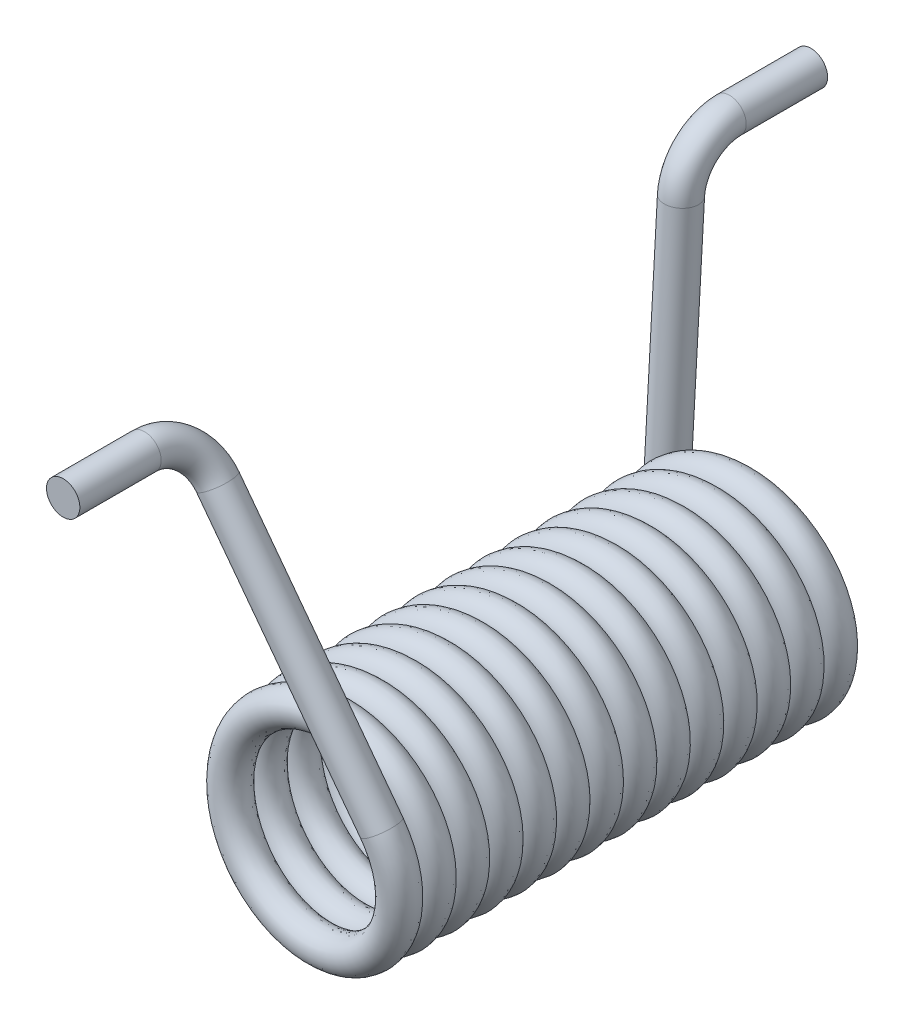
from build123d import *

# Parameters (mm, degrees)
SKIZZE2_R = 2.745


with BuildPart() as part:
    # Austragung1: sweep along a curve in space
    with BuildLine() as austragung1_path:
        Line((-15.25, 53, -10.596174722), (-15.25, 53, -23.975))
        ThreePointArc((-15.25, 45.458446529, -2.60932135), (-15.25, 50.81668171, -5.103796923), (-15.25, 53, -10.596174722))
        Line((-15.25, 0, 0), (-15.25, 45.458446529, -2.60932135))
        add(Edge.make_bspline(
            [(-15.25, 0, 0), (-15.25, -1.844708591, 0.105886538), (-14.565570074, -5.568957736, 0.319695886), (-11.620831046, -10.394587854, 0.638773055), (-7.145781306, -13.858725176, 0.958288818), (-1.729726086, -15.495884383, 1.277687059), (3.914111324, -15.092966114, 1.597116791), (9.042511718, -12.702361416, 1.916538085), (12.980132167, -8.639060495, 2.235961639), (15.208439811, -3.438098717, 2.555384588), (15.433995821, 2.215612758, 2.8748077), (13.627097435, 7.577557881, 3.194230767), (10.025689423, 11.94163803, 3.513653847), (5.104029883, 14.733161455, 3.833076923), (-0.489763308, 15.584521145, 4.1525), (-6.019061108, 14.383604236, 4.471923077), (-10.755727671, 11.288555697, 4.791346154), (-14.076006265, 6.706952741, 5.110769231), (-15.54265984, 1.24213226, 5.430192308), (-14.962549395, -4.386260713, 5.749615385), (-12.412067853, -9.437040801, 6.069038462), (-8.227080109, -13.245086649, 6.388461538), (-2.958694046, -15.308928669, 6.707884615), (2.699313135, -15.356785993, 7.027307692), (8.001856255, -13.382356441, 7.346730769), (12.250660076, -9.645646435, 7.666153846), (14.88621298, -4.638731568, 7.985576923), (15.561447288, 0.979043278, 8.305), (14.187443517, 6.467890992, 8.624423077), (10.945139905, 11.105002472, 8.943846154), (6.261505223, 14.279731083, 9.263269231), (0.753312599, 15.574006793, 9.582692308), (-4.854081393, 14.817390502, 9.902115385), (-9.822256664, 12.109518631, 10.221538462), (-13.496969829, 7.806982316, 10.540961538), (-15.394309463, 2.476369039, 10.860384615), (-15.264420872, -3.180349492, 11.179807692), (-13.124408677, -8.418257796, 11.499230769), (-9.256084358, -12.547592192, 11.818653846), (-4.168855384, -15.024573612, 12.138076923), (1.467357051, -15.523016161, 12.4575), (6.910337849, -13.977281505, 12.776923077), (11.443317976, -10.590922582, 13.096346154), (14.469363529, -5.809878355, 13.415769231), (15.589984081, -0.26374951, 13.735192308), (14.657608633, 5.31711168, 14.054615385), (11.795018777, 10.197779145, 14.374038462), (7.379179974, 13.73553313, 14.693461538), (1.991600155, 15.464497931, 15.012884615), (-3.658247228, 15.15699161, 15.332307692), (-8.826351533, 12.853508707, 15.651730769), (-12.832141348, 8.857387644, 15.971153846), (-15.148106804, 3.694865044, 16.290576923), (-15.469265691, -1.95422272, 16.61), (-13.753325603, -7.345965036, 16.929423077), (-10.226253297, -11.770340307, 17.248846154), (-5.352517839, -14.644716461, 17.568269231), (0.226073869, -15.590575937, 17.887692308), (5.77489462, -14.483361474, 18.207115385), (10.56323765, -11.468878664, 18.526538462), (13.960541118, -6.944095272, 18.845961538), (15.519424808, -1.504865802, 19.165384615), (15.034604227, 4.132534716, 19.484807692), (12.569923874, 9.225734726, 19.804230769), (8.449949757, 13.10402673, 20.123653846), (3.217228318, 15.256690644, 20.443076923), (-2.439159807, 15.400248923, 20.7625), (-7.774342643, 13.515796829, 21.081923077), (-12.085746734, 9.851491935, 21.401346154), (-14.805616826, 4.889875034, 21.720769231), (-15.575781777, -0.71567414, 22.040192308), (-14.294820986, -6.226978436, 22.359615385), (-11.131420151, -10.918271514, 22.679038462), (-6.502157587, -14.171771737, 22.998461538), (-1.016646328, -15.559035886, 23.317884615), (4.602743891, -14.897379505, 23.637307692), (9.616013234, -12.273934045, 23.956730769), (13.36298002, -8.034172791, 24.276153846), (15.350217972, -2.736416576, 24.595576923), (15.316033969, 2.921689737, 24.915), (13.264929595, 8.195047912, 25.234423077), (9.467008339, 12.389225987, 25.553846154), (4.422406513, 14.951905835, 25.873269231), (-1.204568127, 15.545616201, 26.192692308), (-6.672916976, 14.092173235, 26.512115385), (-11.262530363, 10.782976271, 26.831538462), (-14.369016529, 6.053803057, 27.150961538), (-15.583292074, 0.527423546, 27.470384615), (-14.745452868, -5.068410713, 27.789807692), (-11.965831324, -9.996801897, 28.109230769), (-7.610467065, -13.608745662, 28.428653846), (-2.252904321, -15.428596487, 28.748076923), (3.401336313, -15.216703938, 29.0675), (8.607665658, -13.000971478, 29.386923077), (12.68047857, -9.07318195, 29.706346154), (15.083439117, -3.95057361, 30.025769231), (15.500108979, 1.69227335, 30.345192308), (13.875618211, 7.112270152, 30.664615385), (10.423890896, 11.595674454, 30.984038462), (5.599474154, 14.552080836, 31.303461538), (0.037680262, 15.592169434, 31.622884615), (-5.529075626, 14.57897425, 31.942307692), (-10.367724924, 11.645919773, 32.261730769), (-13.841081115, 7.179250728, 32.581153846), (-15.491748841, 1.767168721, 32.900576923), (-15.102356858, -3.87762618, 33.22), (-12.724182971, -9.011788678, 33.539423077), (-8.670401425, -12.959217051, 33.858846154), (-3.474841968, -15.200086866, 34.178269231), (2.178308504, -15.43930502, 34.497692308), (7.544604377, -13.645369627, 34.817115385), (11.917375014, -10.054518398, 35.136538462), (14.720783996, -5.139619246, 35.455961538), (15.585659205, 0.452100209, 35.775384615), (14.398107944, 5.984284008, 36.094807692), (11.314515105, 10.728416257, 36.414230769), (6.740949337, 14.059757092, 36.733653846), (1.27968914, 15.539612709, 37.053076923), (-4.350089298, 14.973105575, 37.3725), (-9.40701815, 12.434837232, 37.691923077), (-13.22516635, 8.25906426, 38.011346154), (-15.301733965, 2.995681077, 38.330769231), (-15.363264332, -2.662193931, 38.650192308), (-13.40165471, -7.969492988, 38.969615385), (-9.675223305, -12.227314564, 39.289038462), (-4.674692155, -14.874959519, 39.608461538), (0.941434511, -15.563767812, 39.927884615), (6.433586625, -14.203032443, 40.247307692), (11.07851994, -10.971944376, 40.566730769), (14.264557786, -6.295995443, 40.886153846), (15.572140856, -0.790946659, 41.205576923), (14.829077644, 4.818259403, 41.525), (12.133219809, 9.792964031, 41.844423077), (7.839576397, 13.478064007, 42.163846154), (2.51356381, 15.3882801, 42.483269231), (-3.143452093, 15.272061956, 42.802692308), (-8.386516672, 13.144713978, 43.122115385), (-12.525187231, 9.286379934, 43.441538462), (-15.014455254, 4.205151707, 43.760961538), (-15.52651686, -1.429839731, 44.080384615), (-13.993940265, -6.876540069, 44.399807692), (-10.618545663, -11.41769046, 44.719230769), (-5.844828161, -14.455281084, 45.038653846), (-0.30142361, -15.589301179, 45.358076923), (5.281674469, -14.670415204, 45.6775), (10.169245438, -11.819628364, 45.996923077), (13.717660441, -7.412351818, 46.316346154), (15.459639859, -2.028965959, 46.635769231), (15.165787899, 3.621608048, 46.955192308), (12.874801001, 8.795263876, 47.274615385), (8.888372028, 12.81069905, 47.594038462), (3.731461282, 15.139133534, 47.913461538), (-1.916833872, 15.47394311, 48.232884615), (-7.312707198, 13.771037756, 48.552307692), (-11.745593099, 10.254667728, 48.871730769), (-14.631738765, 5.38789274, 49.191153846), (-15.591076745, -0.188396908, 49.510576923), (-14.497274835, -5.739877159, 49.83), (-11.494372373, -10.535491028, 50.149423077), (-6.977812142, -13.943719201, 50.468846154), (-1.542365764, -15.515742821, 50.788269231), (4.096189913, -15.04454704, 51.107692308), (9.195331216, -12.592182149, 51.427115385), (13.083568256, -8.481592371, 51.746538462), (15.248871317, -3.254088355, 52.065961538), (15.406098446, 2.401936329, 52.385384615), (13.534544897, 7.741657567, 52.704807692), (9.880669673, 12.061904255, 53.024230769), (4.925640118, 14.793756686, 53.343653846), (-0.678031501, 15.577465799, 53.663076923), (-6.192415283, 14.309827407, 53.9825), (-10.891339361, 11.157772823, 54.301923077), (-14.156017193, 6.536386209, 54.621346154), (-15.556533618, 1.05424344, 54.940769231), (-14.90845903, -4.566729333, 55.260192308), (-12.297136334, -9.586323875, 55.579615385), (-8.066442407, -13.343525559, 55.899038462), (-2.773504035, -15.343560304, 56.218461538), (2.884668365, -15.323049823, 56.537884615), (8.162967856, -13.284695075, 56.857307692), (12.366311768, -9.496920591, 57.176730769), (14.941174955, -4.458526485, 57.496153846), (15.548481776, 1.166996958, 57.815576923), (14.108257906, 6.638842241, 58.135), (10.810161899, 11.236439256, 58.454423077), (6.088509651, 14.354344906, 58.773846154), (0.565080705, 15.581971995, 59.093269231), (-5.032761943, 14.75765817, 59.412692308), (-9.96785599, 11.989954729, 59.732115385), (-13.590314414, 7.643331838, 60.051538462), (-15.423107051, 2.290182602, 60.370961538), (-15.2248792, -3.364553582, 60.690384615), (-13.021734863, -8.57622228, 61.009807692), (-9.103799194, -12.658515224, 61.329230769), (-3.987012825, -15.073848088, 61.648653846), (1.654810731, -15.504153279, 61.968076923), (7.078717463, -13.892765258, 62.2875), (11.570450143, -10.45188265, 62.606923077), (14.538506613, -5.634624469, 62.926346154), (15.592032846, -0.075360303, 63.245769231), (14.592293284, 5.493827824, 63.565192308), (11.670940488, 10.339551034, 63.884615385), (7.212678223, 13.823691269, 64.204038462), (1.804601036, 15.487433052, 64.523461538), (-3.84111839, 15.111683459, 64.842884615), (-8.981013009, 12.745923771, 65.162307692), (-12.938226254, 8.701693447, 65.481730769), (-15.191645153, 3.511564464, 65.801153846), (-15.444524054, -2.140991405, 66.120576923), (-13.663562129, -7.511606846, 66.44), (-10.083288655, -11.893042392, 66.759423077), (-5.175178594, -14.708320569, 67.078846154), (0.41443447, -15.586706243, 67.398269231), (5.94947196, -14.412527566, 67.717692308), (10.70104219, -11.340408436, 68.037115385), (14.04342581, -6.774906566, 68.356538462), (15.536474827, -1.317238546, 68.675961538), (14.983574311, 4.313892478, 68.995384615), (12.457533992, 9.376940562, 69.314807692), (8.291000178, 13.205168817, 69.634230769), (3.032650613, 15.294449899, 69.953653846), (-2.625059179, 15.369652949, 70.273076923), (-7.937083179, 13.420874712, 70.5925), (-12.203897646, 9.704743674, 70.911923077), (-14.863619184, 4.710625434, 71.231346153), (-15.565997461, -0.903820218, 71.550769233), (-14.218538357, -6.399244791, 71.8701923), (-10.998685019, -11.051972318, 72.189615412), (-6.330447969, -14.249302643, 72.509038361), (-0.828579554, -15.570178535, 72.828461915), (4.782422165, -14.840698495, 73.147883209), (9.763566103, -12.15677433, 73.467312941), (13.459259, -7.872407583, 73.786711182), (15.381490865, -2.549688145, 74.106226945), (15.282114339, 3.102596198, 74.425304114), (13.864445156, 6.613819645, 74.639113462), (12.876000864, 8.171358623, 74.745)],
            knots=[0, 0, 0, 0, 0.004273504, 0.008547009, 0.012820513, 0.017094017, 0.021367521, 0.025641026, 0.02991453, 0.034188034, 0.038461538, 0.042735043, 0.047008547, 0.051282051, 0.055555556, 0.05982906, 0.064102564, 0.068376068, 0.072649573, 0.076923077, 0.081196581, 0.085470085, 0.08974359, 0.094017094, 0.098290598, 0.102564103, 0.106837607, 0.111111111, 0.115384615, 0.11965812, 0.123931624, 0.128205128, 0.132478632, 0.136752137, 0.141025641, 0.145299145, 0.14957265, 0.153846154, 0.158119658, 0.162393162, 0.166666667, 0.170940171, 0.175213675, 0.179487179, 0.183760684, 0.188034188, 0.192307692, 0.196581197, 0.200854701, 0.205128205, 0.209401709, 0.213675214, 0.217948718, 0.222222222, 0.226495726, 0.230769231, 0.235042735, 0.239316239, 0.243589744, 0.247863248, 0.252136752, 0.256410256, 0.260683761, 0.264957265, 0.269230769, 0.273504274, 0.277777778, 0.282051282, 0.286324786, 0.290598291, 0.294871795, 0.299145299, 0.303418803, 0.307692308, 0.311965812, 0.316239316, 0.320512821, 0.324786325, 0.329059829, 0.333333333, 0.337606838, 0.341880342, 0.346153846, 0.35042735, 0.354700855, 0.358974359, 0.363247863, 0.367521368, 0.371794872, 0.376068376, 0.38034188, 0.384615385, 0.388888889, 0.393162393, 0.397435897, 0.401709402, 0.405982906, 0.41025641, 0.414529915, 0.418803419, 0.423076923, 0.427350427, 0.431623932, 0.435897436, 0.44017094, 0.444444444, 0.448717949, 0.452991453, 0.457264957, 0.461538462, 0.465811966, 0.47008547, 0.474358974, 0.478632479, 0.482905983, 0.487179487, 0.491452991, 0.495726496, 0.5, 0.504273504, 0.508547009, 0.512820513, 0.517094017, 0.521367521, 0.525641026, 0.52991453, 0.534188034, 0.538461538, 0.542735043, 0.547008547, 0.551282051, 0.555555556, 0.55982906, 0.564102564, 0.568376068, 0.572649573, 0.576923077, 0.581196581, 0.585470085, 0.58974359, 0.594017094, 0.598290598, 0.602564103, 0.606837607, 0.611111111, 0.615384615, 0.61965812, 0.623931624, 0.628205128, 0.632478632, 0.636752137, 0.641025641, 0.645299145, 0.64957265, 0.653846154, 0.658119658, 0.662393162, 0.666666667, 0.670940171, 0.675213675, 0.679487179, 0.683760684, 0.688034188, 0.692307692, 0.696581197, 0.700854701, 0.705128205, 0.709401709, 0.713675214, 0.717948718, 0.722222222, 0.726495726, 0.730769231, 0.735042735, 0.739316239, 0.743589744, 0.747863248, 0.752136752, 0.756410256, 0.760683761, 0.764957265, 0.769230769, 0.773504274, 0.777777778, 0.782051282, 0.786324786, 0.790598291, 0.794871795, 0.799145299, 0.803418803, 0.807692308, 0.811965812, 0.816239316, 0.820512821, 0.824786325, 0.829059829, 0.833333333, 0.837606838, 0.841880342, 0.846153846, 0.85042735, 0.854700855, 0.858974359, 0.863247863, 0.867521368, 0.871794872, 0.876068376, 0.88034188, 0.884615385, 0.888888889, 0.893162393, 0.897435897, 0.901709402, 0.905982906, 0.91025641, 0.914529915, 0.918803419, 0.923076923, 0.927350427, 0.931623932, 0.935897436, 0.94017094, 0.944444444, 0.948717949, 0.952991453, 0.957264957, 0.961538462, 0.965811966, 0.97008547, 0.974358974, 0.978632479, 0.982905983, 0.987179487, 0.991452991, 0.995726496, 1, 1, 1, 1], degree=3))
        Line((12.876000864, 8.171358623, 74.745), (-11.481852844, 46.553194478, 77.35432135))
        ThreePointArc((-11.481852844, 46.553194478, 77.35432135), (-14.352938828, 51.077302073, 79.848796923), (-15.52281927, 52.920738675, 85.341174722))
        Line((-15.52281927, 52.920738675, 85.341174722), (-15.52281927, 52.920738675, 98.72))
    # Skizze2 → Austragung1 (sweep)
    with BuildSketch(Plane(origin=(-15.25, 53, -23.975), x_dir=(-1, 0, 0), z_dir=(0, 0, -1))):
        Circle(SKIZZE2_R)
    sweep(path=austragung1_path.line, is_frenet=True)


solid = part.part
